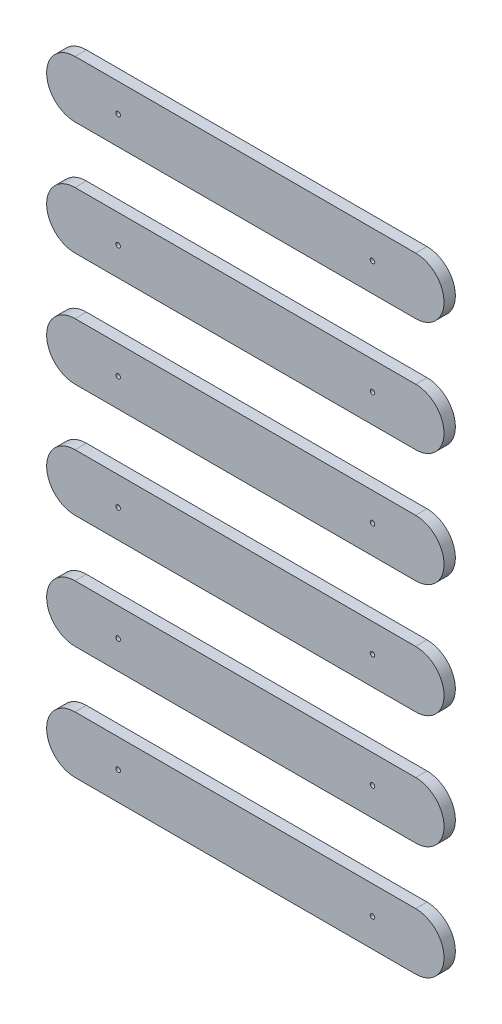
from build123d import *

# Parameters (mm, degrees)
SKETCH1_R           = 0.2
BOSS_EXTRUDE1_DEPTH = 1
LPATTERN1_COUNT     = 6
LPATTERN1_PITCH     = 10


with BuildPart() as part:
    # Sketch1 → Boss-Extrude1 (new body)
    with BuildSketch(Plane.XY):
        with BuildLine():
            Line((-12.826086957, 2.5), (17.173913043, 2.5))
            ThreePointArc((17.173913043, 2.5), (19.673913043, 0), (17.173913043, -2.5))
            Line((17.173913043, -2.5), (-12.826086957, -2.5))
            ThreePointArc((-12.826086957, -2.5), (-15.326086957, 0), (-12.826086957, 2.5))
        make_face()
        with Locations((13.373913043, 0)):
            Circle(SKETCH1_R, mode=Mode.SUBTRACT)
        with Locations((-9.026086957, 0)):
            Circle(SKETCH1_R, mode=Mode.SUBTRACT)
    extrude(amount=BOSS_EXTRUDE1_DEPTH)


with BuildPart() as lpattern1_1:
    # LPattern1: pattern copy
    add(part.part.moved(Location(Vector(0, -1, 0) * (1 * LPATTERN1_PITCH))))


with BuildPart() as lpattern1_2:
    # LPattern1: pattern copy
    add(part.part.moved(Location(Vector(0, -1, 0) * (2 * LPATTERN1_PITCH))))


with BuildPart() as lpattern1_3:
    # LPattern1: pattern copy
    add(part.part.moved(Location(Vector(0, -1, 0) * (3 * LPATTERN1_PITCH))))


with BuildPart() as lpattern1_4:
    # LPattern1: pattern copy
    add(part.part.moved(Location(Vector(0, -1, 0) * (4 * LPATTERN1_PITCH))))


with BuildPart() as lpattern1_5:
    # LPattern1: pattern copy
    add(part.part.moved(Location(Vector(0, -1, 0) * (5 * LPATTERN1_PITCH))))


solid = Compound([part.part, lpattern1_1.part, lpattern1_2.part, lpattern1_3.part, lpattern1_4.part, lpattern1_5.part])
